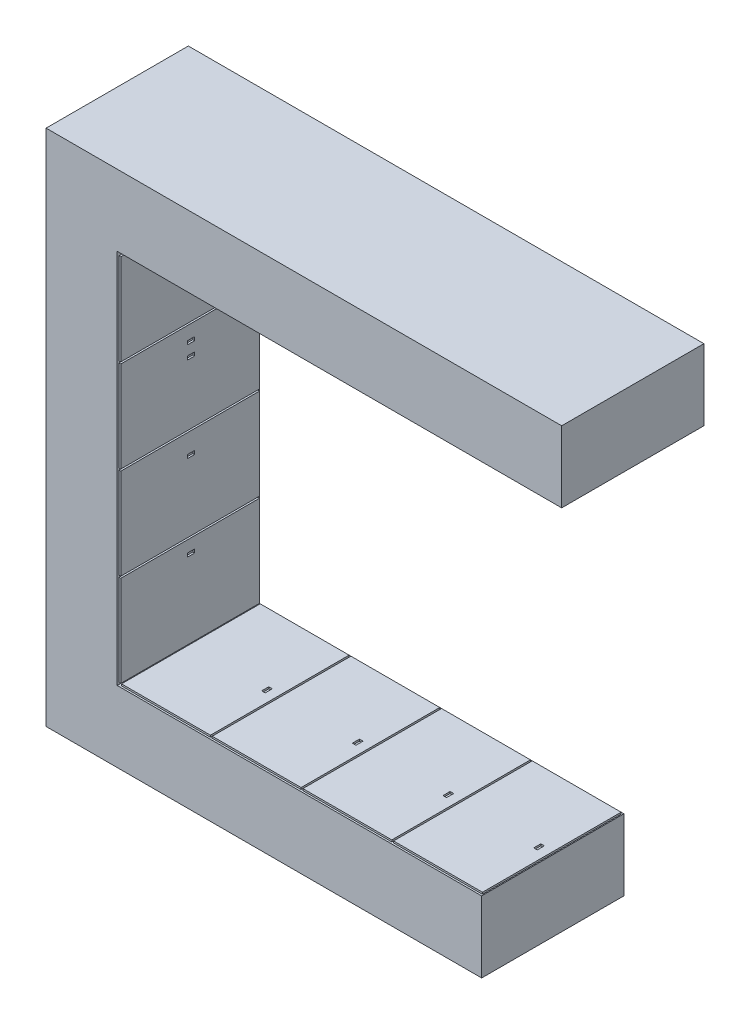
from build123d import *

# Parameters (mm, degrees)
BOSS_EXTRUDE1_DEPTH = 800
SKETCH2_W           = 500
SKETCH2_H           = 780
SKETCH2_W_2         = 20
SKETCH2_H_2         = 40
BOSS_EXTRUDE2_DEPTH = 10
SKETCH3_W           = 780
SKETCH3_H           = 512
SKETCH3_W_2         = 40
SKETCH3_H_2         = 20
BOSS_EXTRUDE3_DEPTH = 10
SKETCH4_W           = 480
SKETCH4_H           = 780
SKETCH4_W_2         = 20
SKETCH4_H_2         = 40
BOSS_EXTRUDE4_DEPTH = 10


with BuildPart() as part:
    # Sketch1 → Boss-Extrude1 (new body)
    with BuildSketch(Plane.XY):
        Polygon((2763.061970043, 160), (-136.938029957, 160), (-136.938029957, -2755), (2313.061970043, -2755), (2313.061970043, -2355), (263.061970043, -2355), (263.061970043, -240), (2763.061970043, -240), align=None)
    extrude(amount=BOSS_EXTRUDE1_DEPTH)

    # Sketch2 → Boss-Extrude2 (add)
    with BuildSketch(Plane(origin=(0, -2355, 0), x_dir=(1, 0, 0), z_dir=(0, 1, 0))):
        with Locations((1037.540108644, -400)):
            Rectangle(SKETCH2_W, SKETCH2_H)
        with Locations((1225.627674913, -410)):
            Rectangle(SKETCH2_W_2, SKETCH2_H_2, mode=Mode.SUBTRACT)
        with Locations((527.540108644, -400)):
            Rectangle(SKETCH2_W, SKETCH2_H)
        with Locations((715.627674913, -410)):
            Rectangle(SKETCH2_W_2, SKETCH2_H_2, mode=Mode.SUBTRACT)
        with Locations((1547.540108644, -400)):
            Rectangle(SKETCH2_W, SKETCH2_H)
        with Locations((1735.627674913, -410)):
            Rectangle(SKETCH2_W_2, SKETCH2_H_2, mode=Mode.SUBTRACT)
        with Locations((2057.540108644, -400)):
            Rectangle(SKETCH2_W, SKETCH2_H)
        with Locations((2245.627674913, -410)):
            Rectangle(SKETCH2_W_2, SKETCH2_H_2, mode=Mode.SUBTRACT)
    extrude(amount=BOSS_EXTRUDE2_DEPTH)

    # Sketch3 → Boss-Extrude3 (add)
    with BuildSketch(Plane(origin=(263.061970043, 0, 0), x_dir=(0, 0, -1), z_dir=(1, 0, 0))):
        with Locations((-400, -1567)):
            Rectangle(SKETCH3_W, SKETCH3_H)
        with Locations((-395, -1427.588446785)):
            Rectangle(SKETCH3_W_2, SKETCH3_H_2, mode=Mode.SUBTRACT)
        with Locations((-400, -2089)):
            Rectangle(SKETCH3_W, SKETCH3_H)
        with Locations((-395, -1907.588446785)):
            Rectangle(SKETCH3_W_2, SKETCH3_H_2, mode=Mode.SUBTRACT)
        with Locations((-400, -1045)):
            Rectangle(SKETCH3_W, SKETCH3_H)
        with Locations((-395, -947.588446785)):
            Rectangle(SKETCH3_W_2, SKETCH3_H_2, mode=Mode.SUBTRACT)
        with Locations((-395, -873.244551229)):
            Rectangle(SKETCH3_W_2, SKETCH3_H_2, mode=Mode.SUBTRACT)
        with Locations((-400, -523)):
            Rectangle(SKETCH3_W, SKETCH3_H)
    extrude(amount=BOSS_EXTRUDE3_DEPTH)

    # Sketch4 → Boss-Extrude4 (add)
    with BuildSketch(Plane.XZ.offset(240)):
        with Locations((536.430909258, 400)):
            Rectangle(SKETCH4_W, SKETCH4_H)
        with Locations((732.985950251, 464)):
            Rectangle(SKETCH4_W_2, SKETCH4_H_2, mode=Mode.SUBTRACT)
        with Locations((1516.430909258, 400)):
            Rectangle(SKETCH4_W, SKETCH4_H)
        with Locations((1712.985950251, 464)):
            Rectangle(SKETCH4_W_2, SKETCH4_H_2, mode=Mode.SUBTRACT)
        with Locations((2006.430909258, 400)):
            Rectangle(SKETCH4_W, SKETCH4_H)
        with Locations((2202.985950251, 464)):
            Rectangle(SKETCH4_W_2, SKETCH4_H_2, mode=Mode.SUBTRACT)
        with Locations((2496.430909258, 400)):
            Rectangle(SKETCH4_W, SKETCH4_H)
        with Locations((2692.985950251, 464)):
            Rectangle(SKETCH4_W_2, SKETCH4_H_2, mode=Mode.SUBTRACT)
        with Locations((1026.430909258, 400)):
            Rectangle(SKETCH4_W, SKETCH4_H)
        with Locations((1222.985950251, 464)):
            Rectangle(SKETCH4_W_2, SKETCH4_H_2, mode=Mode.SUBTRACT)
    extrude(amount=BOSS_EXTRUDE4_DEPTH)


solid = part.part
